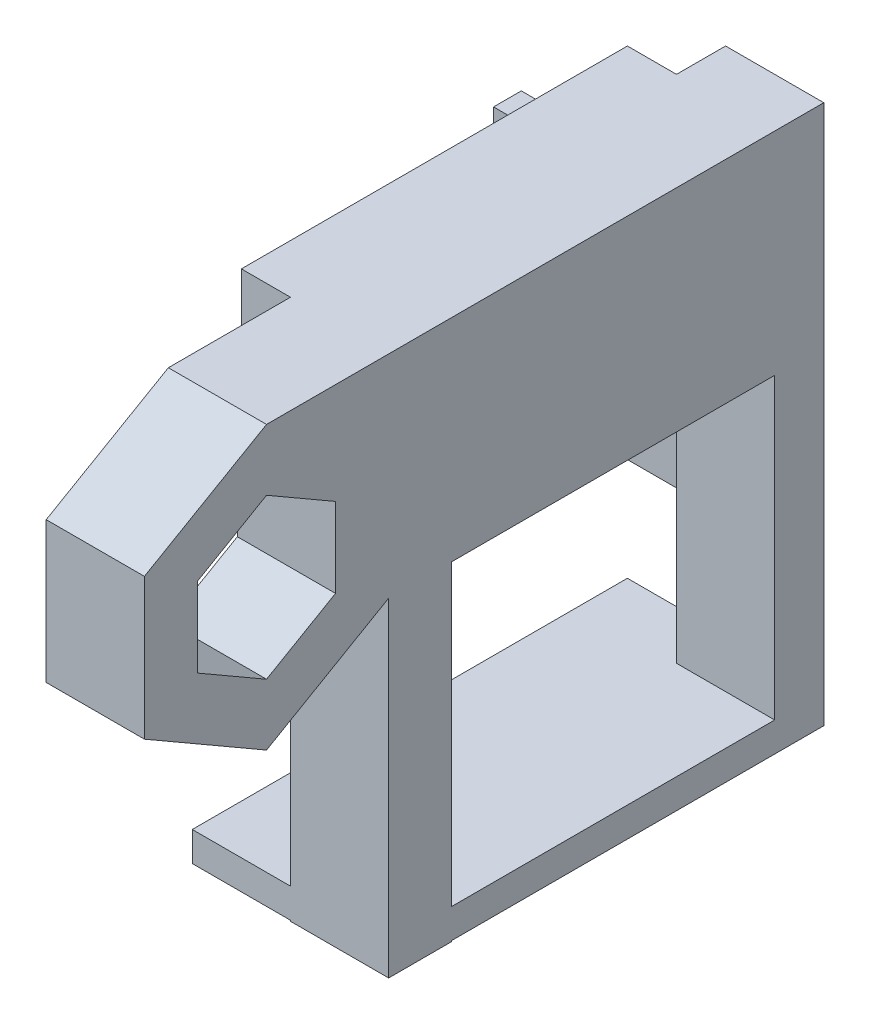
from build123d import *

# Parameters (mm, degrees)
BOSS_EXTRUDE1_DEPTH = 10.16
BOSS_EXTRUDE2_DEPTH = 10.16
SKETCH4_W           = 39.941338686
SKETCH4_H           = 10.470779812
BOSS_EXTRUDE3_DEPTH = 5.08
SKETCH6_W           = 10.16
SKETCH6_H           = 55.829783289
BOSS_EXTRUDE5_DEPTH = 5.08
SKETCH9_W           = 10.16
SKETCH9_H           = 6.478239632
BOSS_EXTRUDE6_DEPTH = 34.036
SKETCH12_W          = 45.021338686
SKETCH12_H          = 3.055969703
BOSS_EXTRUDE7_DEPTH = 10.16
SKETCH13_W          = 10.16
SKETCH13_H          = 3.055969703
BOSS_EXTRUDE8_DEPTH = 33.528
SKETCH16_W          = 2.870015597
SKETCH16_H          = 24.680607417
BOSS_EXTRUDE9_DEPTH = 21.13915


with BuildPart() as part:
    # Sketch2 → Boss-Extrude1 (new body)
    with BuildSketch(Plane(origin=(0, 0, 0), x_dir=(0, 0, -1), z_dir=(1, 0, 0))):
        Polygon((0, 14.591559623), (-12.636661314, 7.295779811), (-12.636661314, -7.295779811), (0, -14.591559623), (12.636661314, -7.295779811), (12.636661314, 7.295779811), align=None)
        Polygon((0, 8.241559623), (-7.1374, 4.120779811), (-7.1374, -4.120779811), (0, -8.241559623), (7.1374, -4.120779811), (7.1374, 4.120779811), align=None, mode=Mode.SUBTRACT)
    extrude(amount=BOSS_EXTRUDE1_DEPTH)

    # Sketch3 → Boss-Extrude2 (add)
    with BuildSketch(Plane(origin=(0, 0, 0), x_dir=(0, 0, -1), z_dir=(1, 0, 0))):
        Polygon((12.636661314, -7.295779811), (52.578, -7.295779811), (52.578, 14.591559623), (0, 14.591559623), (12.636661314, 7.295779811), align=None)
    extrude(amount=BOSS_EXTRUDE2_DEPTH)

    # Sketch4 → Boss-Extrude3 (add)
    with BuildSketch(Plane.ZY):
        with Locations((-32.607330657, 9.356169717)):
            Rectangle(SKETCH4_W, SKETCH4_H)
    extrude(amount=BOSS_EXTRUDE3_DEPTH)

    # Sketch6 → Boss-Extrude5 (add)
    with BuildSketch(Plane(origin=(0, 0, -52.578), x_dir=(-1, 0, 0), z_dir=(0, 0, -1))):
        with Locations((-5.08, -13.323332022)):
            Rectangle(SKETCH6_W, SKETCH6_H)
    extrude(amount=BOSS_EXTRUDE5_DEPTH)

    # Sketch9 → Boss-Extrude6 (add)
    with BuildSketch(Plane(origin=(0, -7.295779811, 0), x_dir=(-1, 0, 0), z_dir=(0, -1, 0))):
        with Locations((-5.08, 15.87578113)):
            Rectangle(SKETCH9_W, SKETCH9_H)
    extrude(amount=BOSS_EXTRUDE6_DEPTH)

    # Sketch12 → Boss-Extrude7 (add)
    with BuildSketch(Plane.ZY):
        with Locations((-35.147330657, -39.710238815)):
            Rectangle(SKETCH12_W, SKETCH12_H)
    extrude(amount=BOSS_EXTRUDE7_DEPTH)

    # Sketch13 → Boss-Extrude8 (add)
    with BuildSketch(Plane.XY.offset(-52.578)):
        with Locations((5.08, -39.710238815)):
            Rectangle(SKETCH13_W, SKETCH13_H)
    extrude(amount=BOSS_EXTRUDE8_DEPTH)

    # Sketch16 → Boss-Extrude9 (add)
    with BuildSketch(Plane.ZY):
        with Locations((-56.222992202, -12.340303709)):
            Rectangle(SKETCH16_W, SKETCH16_H)
    extrude(amount=BOSS_EXTRUDE9_DEPTH)


solid = part.part
